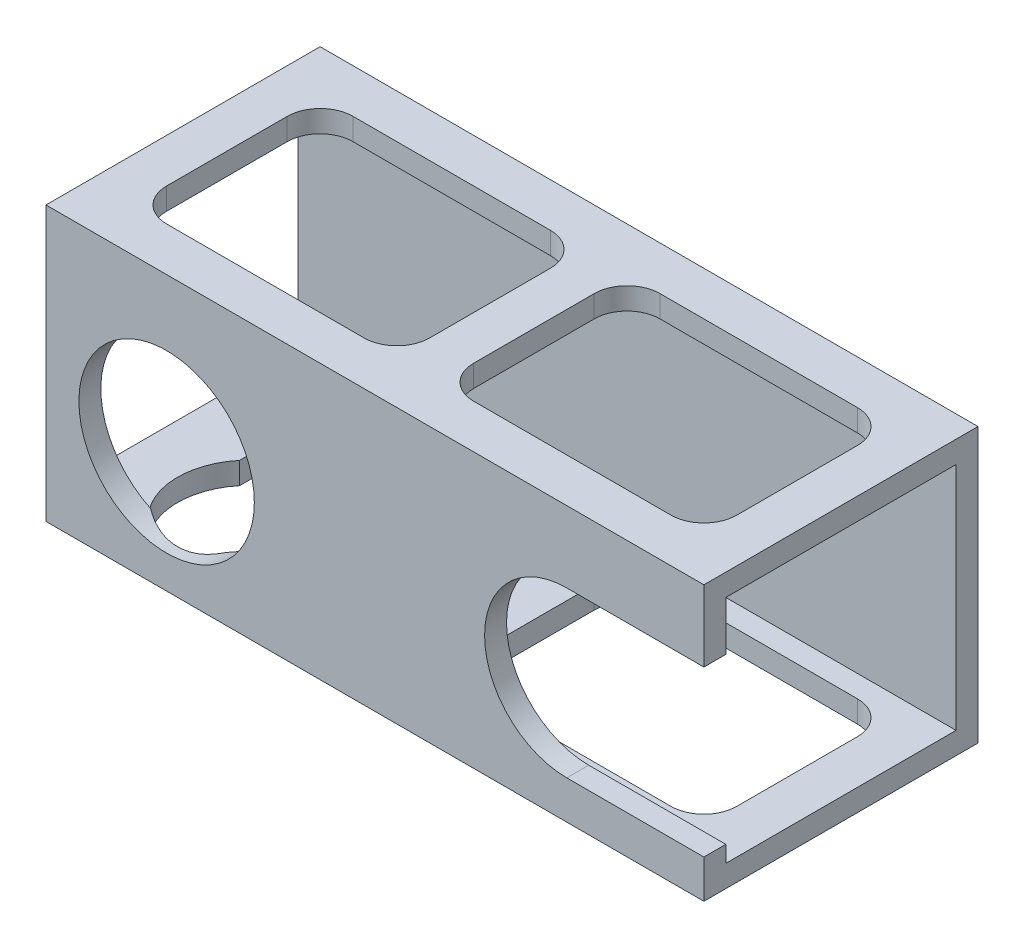
from build123d import *

# Parameters (mm, degrees)
SKETCH_1_W          = 25
SKETCH_1_H          = 25
SKETCH_1_W_2        = 21
SKETCH_1_H_2        = 21
EXTRUDE_1_DEPTH     = 60
CUT_EXTRUDE_1_REACH = 71.642
SKETCH_2_R          = 8
SKETCH_2_R_2        = 7.5
SKETCH_3_R          = 6.5
CUT_EXTRUDE_2_DEPTH = 4.5
CUT_EXTRUDE_3_DEPTH = 2.5
CUT_EXTRUDE_4_REACH = 71.642
CUT_EXTRUDE_5_REACH = 71.642
CUT_EXTRUDE_6_REACH = 71.642


with BuildPart() as part:
    # Эскиз1 → Бобышка-Вытянуть1 (new body)
    with BuildSketch(Plane(origin=(0, 0, 0), x_dir=(0, 0, -1), z_dir=(1, 0, 0))):
        with Locations((12.5, 12.5)):
            Rectangle(SKETCH_1_W, SKETCH_1_H)
        with Locations((12.5, 12.5)):
            Rectangle(SKETCH_1_W_2, SKETCH_1_H_2, mode=Mode.SUBTRACT)
    extrude(amount=EXTRUDE_1_DEPTH)

    # Эскиз2 → Вырез-Вытянуть1 (cut, up to next)
    with BuildSketch(Plane.XY, mode=Mode.PRIVATE) as cut_extrude_1_sk1:
        with Locations((11, 11)):
            Circle(SKETCH_2_R)
    cut_extrude_1_tool1 = extrude(cut_extrude_1_sk1.sketch, amount=-CUT_EXTRUDE_1_REACH, mode=Mode.PRIVATE) & part.part
    # Эскиз2 → Вырез-Вытянуть1 (cut, up to next)
    with BuildSketch(Plane.XY, mode=Mode.PRIVATE) as cut_extrude_1_sk2:
        with Locations((47.5, 11)):
            Circle(SKETCH_2_R_2)
    cut_extrude_1_tool2 = extrude(cut_extrude_1_sk2.sketch, amount=-CUT_EXTRUDE_1_REACH, mode=Mode.PRIVATE) & part.part
    add(cut_extrude_1_tool1.solids().sort_by_distance((11, 11, 0))[0], mode=Mode.SUBTRACT)
    add(cut_extrude_1_tool2.solids().sort_by_distance((47.5, 11, 0))[0], mode=Mode.SUBTRACT)

    # Эскиз3 → Вырез-Вытянуть2 (cut)
    with BuildSketch(Plane.XZ):
        with Locations((11, -7.5)):
            Circle(SKETCH_3_R)
    extrude(amount=-CUT_EXTRUDE_2_DEPTH, mode=Mode.SUBTRACT)

    # Эскиз4 → Вырез-Вытянуть3 (cut)
    with BuildSketch(Plane(origin=(0, 0, 0), x_dir=(1, 0, 0), z_dir=(0, 1, 0))):
        with BuildLine():
            Line((16, 11.653311931), (16, 25))
            Line((16, 25), (6, 25))
            Line((6, 25), (6, 11.653311931))
            ThreePointArc((6, 11.653311931), (11, 14), (16, 11.653311931))
        make_face()
    extrude(amount=CUT_EXTRUDE_3_DEPTH, mode=Mode.SUBTRACT)

    # Эскиз5 → Вырез-Вытянуть4 (cut, up to next)
    with BuildSketch(Plane.XY, mode=Mode.PRIVATE) as cut_extrude_4_sk1:
        with BuildLine():
            Line((60, 18.5), (47.5, 18.5))
            ThreePointArc((47.5, 18.5), (52.803300859, 16.303300859), (55, 11))
            ThreePointArc((55, 11), (52.803300859, 5.696699141), (47.5, 3.5))
            Line((47.5, 3.5), (60, 3.5))
            Line((60, 3.5), (60, 18.5))
        make_face()
    cut_extrude_4_tool1 = extrude(cut_extrude_4_sk1.sketch, amount=-CUT_EXTRUDE_4_REACH, mode=Mode.PRIVATE) & part.part
    add(cut_extrude_4_tool1.solids().sort_by_distance((56.483263, 11, 0))[0], mode=Mode.SUBTRACT)

    # Эскиз6 → Вырез-Вытянуть5 (cut, up to next)
    with BuildSketch(Plane(origin=(0, 25, 0), x_dir=(1, 0, 0), z_dir=(0, 1, 0)), mode=Mode.PRIVATE) as cut_extrude_5_sk1:
        with BuildLine():
            ThreePointArc((4, 7), (4.878679656, 4.878679656), (7, 4))
            Line((7, 4), (25, 4))
            ThreePointArc((25, 4), (27.121320344, 4.878679656), (28, 7))
            Line((28, 7), (28, 18))
            ThreePointArc((28, 18), (27.121320344, 20.121320344), (25, 21))
            Line((25, 21), (7, 21))
            ThreePointArc((7, 21), (4.878679656, 20.121320344), (4, 18))
            Line((4, 18), (4, 7))
        make_face()
    cut_extrude_5_tool1 = extrude(cut_extrude_5_sk1.sketch, amount=-CUT_EXTRUDE_5_REACH, mode=Mode.PRIVATE) & part.part
    # Эскиз6 → Вырез-Вытянуть5 (cut, up to next)
    with BuildSketch(Plane(origin=(0, 25, 0), x_dir=(1, 0, 0), z_dir=(0, 1, 0)), mode=Mode.PRIVATE) as cut_extrude_5_sk2:
        with BuildLine():
            Line((32, 18), (32, 7))
            ThreePointArc((32, 7), (32.878679656, 4.878679656), (35, 4))
            Line((35, 4), (53, 4))
            ThreePointArc((53, 4), (55.121320344, 4.878679656), (56, 7))
            Line((56, 7), (56, 18))
            ThreePointArc((56, 18), (55.121320344, 20.121320344), (53, 21))
            Line((53, 21), (35, 21))
            ThreePointArc((35, 21), (32.878679656, 20.121320344), (32, 18))
        make_face()
    cut_extrude_5_tool2 = extrude(cut_extrude_5_sk2.sketch, amount=-CUT_EXTRUDE_5_REACH, mode=Mode.PRIVATE) & part.part
    add(cut_extrude_5_tool1.solids().sort_by_distance((16, 25, -12.5))[0], mode=Mode.SUBTRACT)
    add(cut_extrude_5_tool2.solids().sort_by_distance((44, 25, -12.5))[0], mode=Mode.SUBTRACT)

    # Эскиз6<3> → Вырез-Вытянуть6 (cut, up to next)
    with BuildSketch(Plane(origin=(0, 25, 0), x_dir=(1, 0, 0), z_dir=(0, 1, 0)), mode=Mode.PRIVATE) as cut_extrude_6_sk1:
        with BuildLine():
            Line((32, 18), (32, 7))
            ThreePointArc((32, 7), (32.878679656, 4.878679656), (35, 4))
            Line((35, 4), (53, 4))
            ThreePointArc((53, 4), (55.121320344, 4.878679656), (56, 7))
            Line((56, 7), (56, 18))
            ThreePointArc((56, 18), (55.121320344, 20.121320344), (53, 21))
            Line((53, 21), (35, 21))
            ThreePointArc((35, 21), (32.878679656, 20.121320344), (32, 18))
        make_face()
    cut_extrude_6_tool1 = extrude(cut_extrude_6_sk1.sketch, amount=-CUT_EXTRUDE_6_REACH, mode=Mode.PRIVATE) & part.part
    add(cut_extrude_6_tool1.solids().sort_by_distance((44, 25, -12.5))[0], mode=Mode.SUBTRACT)


solid = part.part
